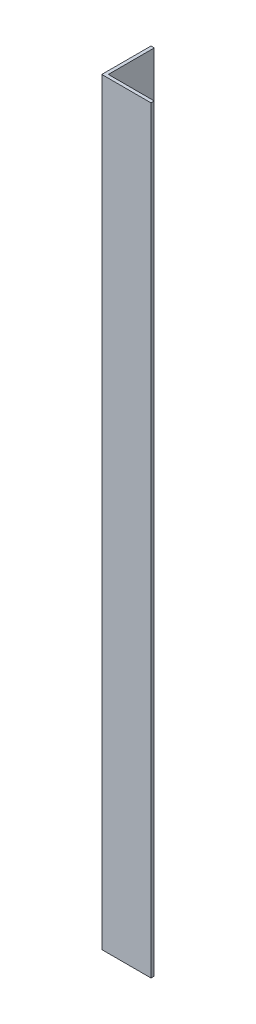
from build123d import *

# Parameters (mm, degrees)
EXTRUDE_1_DEPTH = 231


with BuildPart() as part:
    # Эскиз1 → Бобышка-Вытянуть1 (new body)
    with BuildSketch(Plane(origin=(0, 0, 0), x_dir=(1, 0, 0), z_dir=(0, 1, 0))):
        Polygon((0, 0), (0, 15), (1, 15), (1, 1), (15, 1), (15, 0), align=None)
    extrude(amount=EXTRUDE_1_DEPTH)


solid = part.part
